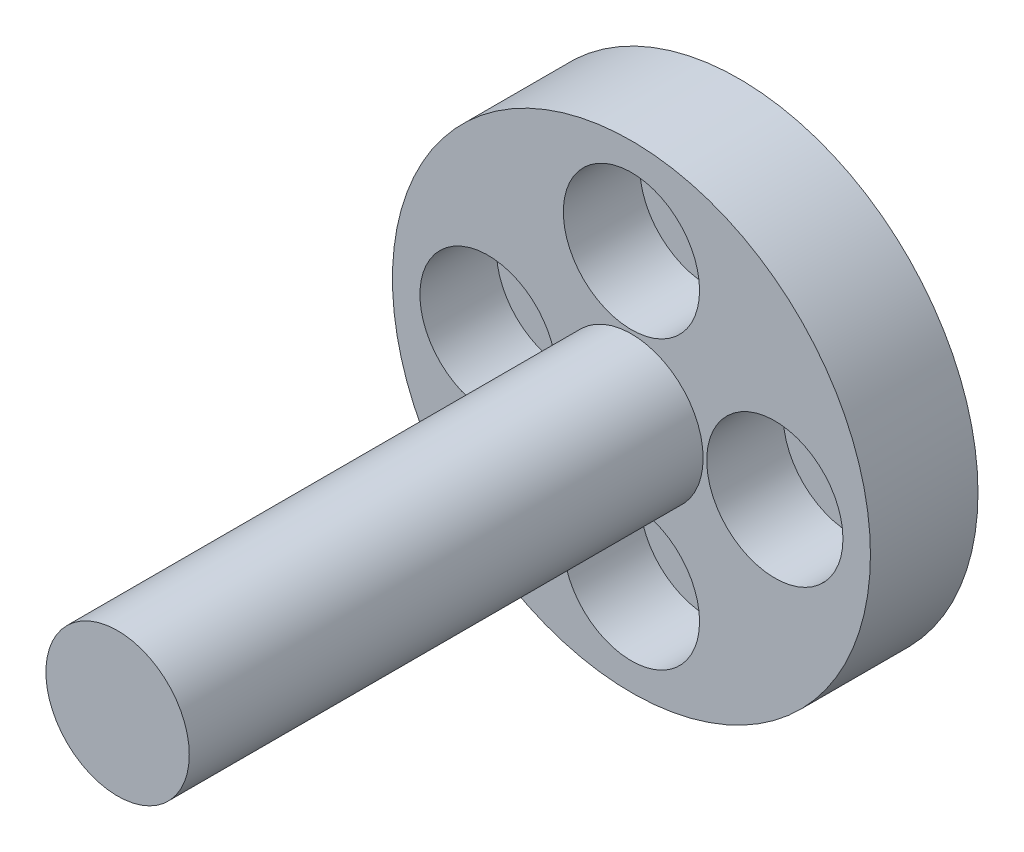
from build123d import *

# Parameters (mm, degrees)
SKETCH1_R           = 10
BOSS_EXTRUDE1_DEPTH = 4.5
SKETCH2_R           = 3
BOSS_EXTRUDE2_DEPTH = 21.5
SKETCH3_R           = 2
CUT_EXTRUDE1_DEPTH  = 6.5
SKETCH4_R           = 1.6
CUT_EXTRUDE2_DEPTH  = 27
SKETCH5_R           = 2.85
CUT_EXTRUDE3_DEPTH  = 3.2


with BuildPart() as part:
    # Sketch1 → Boss-Extrude1 (new body)
    with BuildSketch(Plane.XY):
        Circle(SKETCH1_R)
    extrude(amount=BOSS_EXTRUDE1_DEPTH)

    # Sketch2 → Boss-Extrude2 (add)
    with BuildSketch(Plane.XY.offset(4.5)):
        Circle(SKETCH2_R)
    extrude(amount=BOSS_EXTRUDE2_DEPTH)

    # Sketch3 → Cut-Extrude1 (cut)
    with BuildSketch(Plane(origin=(0, 0, 0), x_dir=(-1, 0, 0), z_dir=(0, 0, -1))):
        Circle(SKETCH3_R)
    extrude(amount=-CUT_EXTRUDE1_DEPTH, mode=Mode.SUBTRACT)

    # Sketch4 → Cut-Extrude2 (cut, through all)
    with BuildSketch(Plane(origin=(0, 0, 0), x_dir=(-1, 0, 0), z_dir=(0, 0, -1))):
        with Locations((0, 6)):
            Circle(SKETCH4_R)
        with Locations((6, 0)):
            Circle(SKETCH4_R)
        with Locations((0, -6)):
            Circle(SKETCH4_R)
        with Locations((-6, 0)):
            Circle(SKETCH4_R)
    extrude(amount=-CUT_EXTRUDE2_DEPTH, mode=Mode.SUBTRACT)

    # Sketch5 → Cut-Extrude3 (cut)
    with BuildSketch(Plane.XY.offset(4.5)):
        with Locations((0, 6)):
            Circle(SKETCH5_R)
        with Locations((6, 0)):
            Circle(SKETCH5_R)
        with Locations((0, -6)):
            Circle(SKETCH5_R)
        with Locations((-6, 0)):
            Circle(SKETCH5_R)
    extrude(amount=-CUT_EXTRUDE3_DEPTH, mode=Mode.SUBTRACT)


solid = part.part
